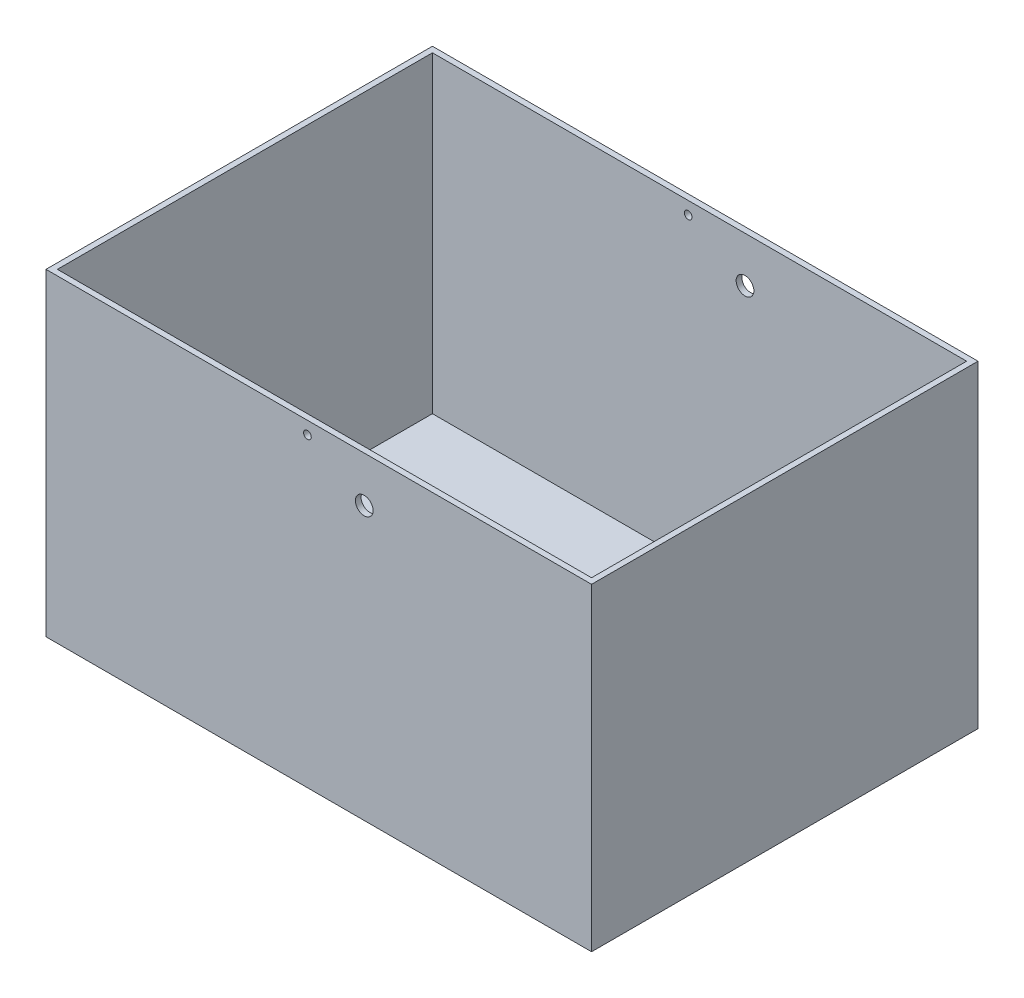
from build123d import *

# Parameters (mm, degrees)
SKETCH1_W               = 298.45
SKETCH1_H               = 209.55
BOSS_EXTRUDE1_DEPTH     = 3.175
SKETCH1_3_W             = 304.8
SKETCH1_3_H             = 215.9
SKETCH1_3_W_2           = 298.45
SKETCH1_3_H_2           = 209.55
BOSS_EXTRUDE2_DEPTH     = 177.8
CUT_EXTRUDE1_DEPTH      = 319.514379581
CUT_EXTRUDE1_DEPTH_BACK = 319.514379581
SKETCH2_R               = 4.953
SKETCH2_R_2             = 2.15


with BuildPart() as part:
    # Sketch1 → Boss-Extrude1 (new body)
    with BuildSketch(Plane(origin=(0, 0, 0), x_dir=(1, 0, 0), z_dir=(0, 1, 0))):
        Rectangle(SKETCH1_W, SKETCH1_H)
    extrude(amount=BOSS_EXTRUDE1_DEPTH)

    # Sketch1_3 → Boss-Extrude2 (add)
    with BuildSketch(Plane(origin=(0, 0, 0), x_dir=(1, 0, 0), z_dir=(0, 1, 0))):
        Rectangle(SKETCH1_3_W, SKETCH1_3_H)
        Rectangle(SKETCH1_3_W_2, SKETCH1_3_H_2, mode=Mode.SUBTRACT)
    extrude(amount=BOSS_EXTRUDE2_DEPTH)

    # Sketch2 → Cut-Extrude1 (cut, two sides: drawn at the far end of the back side and taken through both)
    with BuildSketch(Plane.XY.offset(107.95).offset(-CUT_EXTRUDE1_DEPTH_BACK)):
        with Locations((25.4, 152.4)):
            Circle(SKETCH2_R)
        with Locations((-6.35, 170.7322)):
            Circle(SKETCH2_R_2)
    extrude(amount=CUT_EXTRUDE1_DEPTH + CUT_EXTRUDE1_DEPTH_BACK, mode=Mode.SUBTRACT)


solid = part.part
